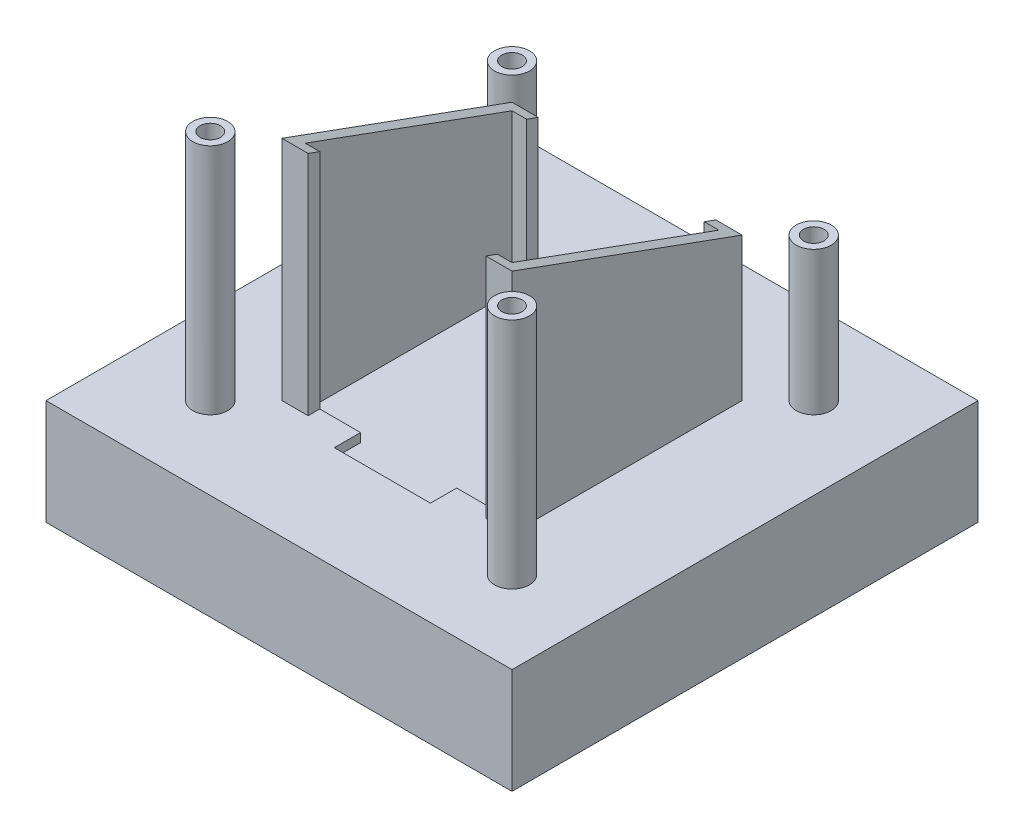
from build123d import *

# Parameters (mm, degrees)
SKETCH1_W               = 80
SKETCH1_H               = 80
BOSS_EXTRUDE1_DEPTH     = 4
CUT_EXTRUDE1_DEPTH      = 1.5
BOSS_EXTRUDE2_DEPTH     = 39
SKETCH5_R               = 3
SKETCH5_R_2             = 1.75
BOSS_EXTRUDE3_DEPTH     = 40
SKETCH6_R               = 4.5
CUT_EXTRUDE2_DEPTH      = 15.39
CUT_EXTRUDE3_DEPTH      = 60.75
SKETCH9_R               = 1.75
CUT_EXTRUDE4_DEPTH      = 41
CUT_EXTRUDE4_DEPTH_BACK = 5
SKETCH10_W              = 80
SKETCH10_H              = 80
SKETCH10_W_2            = 72
SKETCH10_H_2            = 72
BOSS_EXTRUDE5_DEPTH     = 14.1


with BuildPart() as part:
    # Sketch1 → Boss-Extrude1 (new body)
    with BuildSketch(Plane(origin=(0, 0, 0), x_dir=(1, 0, 0), z_dir=(0, 1, 0))):
        Rectangle(SKETCH1_W, SKETCH1_H)
    extrude(amount=BOSS_EXTRUDE1_DEPTH)

    # Sketch2 → Cut-Extrude1 (cut)
    with BuildSketch(Plane(origin=(0, 4, 0), x_dir=(1, 0, 0), z_dir=(0, 1, 0))):
        Polygon((8.25, -17.75), (17.75, -17.75), (17.75, 17.75), (-17.75, 17.75), (-17.75, -17.75), (-8.25, -17.75), (-8.25, -22.25), (8.25, -22.25), align=None)
    extrude(amount=-CUT_EXTRUDE1_DEPTH, mode=Mode.SUBTRACT)

    # Sketch3 → Boss-Extrude2 (add)
    with BuildSketch(Plane(origin=(0, 4, 0), x_dir=(1, 0, 0), z_dir=(0, 1, 0))):
        Polygon((-19.75, 17.75), (-19.75, -17.75), (-19.75, -19.75), (-17.75, -19.75), (-15.25, -19.75), (-15.25, -17.75), (-17.75, -17.75), (-17.75, 17.75), (-15.25, 17.75), (-15.25, 19.75), (-17.75, 19.75), (-19.75, 19.75), align=None)
        Polygon((19.75, 17.75), (19.75, -17.75), (19.75, -19.75), (17.75, -19.75), (15.25, -19.75), (15.25, -17.75), (17.75, -17.75), (17.75, 17.75), (15.25, 17.75), (15.25, 19.75), (17.75, 19.75), (19.75, 19.75), align=None)
    extrude(amount=BOSS_EXTRUDE2_DEPTH)

    # Sketch5 → Boss-Extrude3 (add)
    with BuildSketch(Plane(origin=(0, 4, 0), x_dir=(1, 0, 0), z_dir=(0, 1, 0))):
        with Locations((25.9, 25.9)):
            Circle(SKETCH5_R)
        with Locations((25.9, 25.9)):
            Circle(SKETCH5_R_2, mode=Mode.SUBTRACT)
        with Locations((-25.9, 25.9)):
            Circle(SKETCH5_R)
        with Locations((-25.9, 25.9)):
            Circle(SKETCH5_R_2, mode=Mode.SUBTRACT)
        with Locations((-25.9, -25.9)):
            Circle(SKETCH5_R)
        with Locations((-25.9, -25.9)):
            Circle(SKETCH5_R_2, mode=Mode.SUBTRACT)
        with Locations((25.9, -25.9)):
            Circle(SKETCH5_R)
        with Locations((25.9, -25.9)):
            Circle(SKETCH5_R_2, mode=Mode.SUBTRACT)
    extrude(amount=BOSS_EXTRUDE3_DEPTH)

    # Sketch6 → Cut-Extrude2 (cut)
    with BuildSketch(Plane(origin=(0, 44, 0), x_dir=(1, 0, 0), z_dir=(0, 1, 0))):
        with Locations((-25.9, 25.9)):
            Circle(SKETCH6_R)
        with Locations((25.9, 25.9)):
            Circle(SKETCH6_R)
    extrude(amount=-CUT_EXTRUDE2_DEPTH, mode=Mode.SUBTRACT)

    # Sketch7 → Cut-Extrude3 (cut, through all)
    with BuildSketch(Plane.ZY.offset(19.75)):
        Polygon((-19.75, 28.61), (19.75, 43), (-19.75, 43), align=None)
    extrude(amount=-CUT_EXTRUDE3_DEPTH, mode=Mode.SUBTRACT)

    # Sketch9 → Cut-Extrude4 (cut, two sides)
    with BuildSketch(Plane(origin=(0, 4, 0), x_dir=(1, 0, 0), z_dir=(0, 1, 0))) as cut_extrude4_sk:
        with Locations((-25.9, 25.9)):
            Circle(SKETCH9_R)
        with Locations((-25.9, -25.9)):
            Circle(SKETCH9_R)
        with Locations((25.9, -25.9)):
            Circle(SKETCH9_R)
        with Locations((25.9, 25.9)):
            Circle(SKETCH9_R)
    extrude(amount=CUT_EXTRUDE4_DEPTH, mode=Mode.SUBTRACT)
    extrude(cut_extrude4_sk.sketch, amount=-CUT_EXTRUDE4_DEPTH_BACK, mode=Mode.SUBTRACT)

    # Sketch10 → Boss-Extrude5 (add)
    with BuildSketch(Plane.XZ):
        Rectangle(SKETCH10_W, SKETCH10_H)
        Rectangle(SKETCH10_W_2, SKETCH10_H_2, mode=Mode.SUBTRACT)
    extrude(amount=BOSS_EXTRUDE5_DEPTH)


solid = part.part
